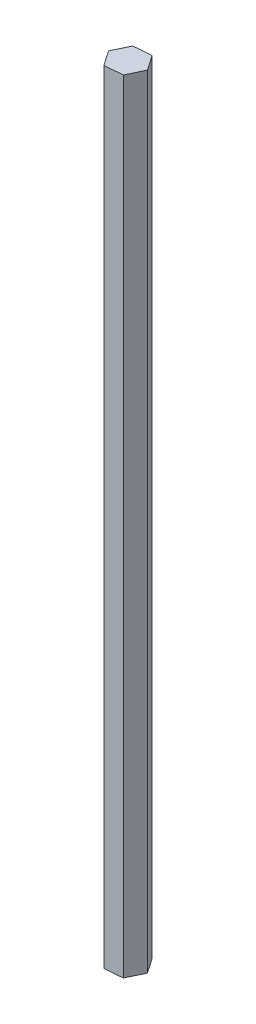
from build123d import *

# Parameters (mm, degrees)
BOSS_EXTRUDE1_DEPTH = 158.75


with BuildPart() as part:
    # Sketch1 → Boss-Extrude1 (new, symmetric)
    with BuildSketch(Plane(origin=(0, 0, 0), x_dir=(1, 0, 0), z_dir=(0, 1, 0))):
        Polygon((7.311389291, 0.554003575), (3.175913476, 6.608850651), (-4.135475816, 6.054847076), (-7.311389291, -0.554003575), (-3.175913476, -6.608850651), (4.135475816, -6.054847076), align=None)
    extrude(amount=BOSS_EXTRUDE1_DEPTH, both=True)


solid = part.part
